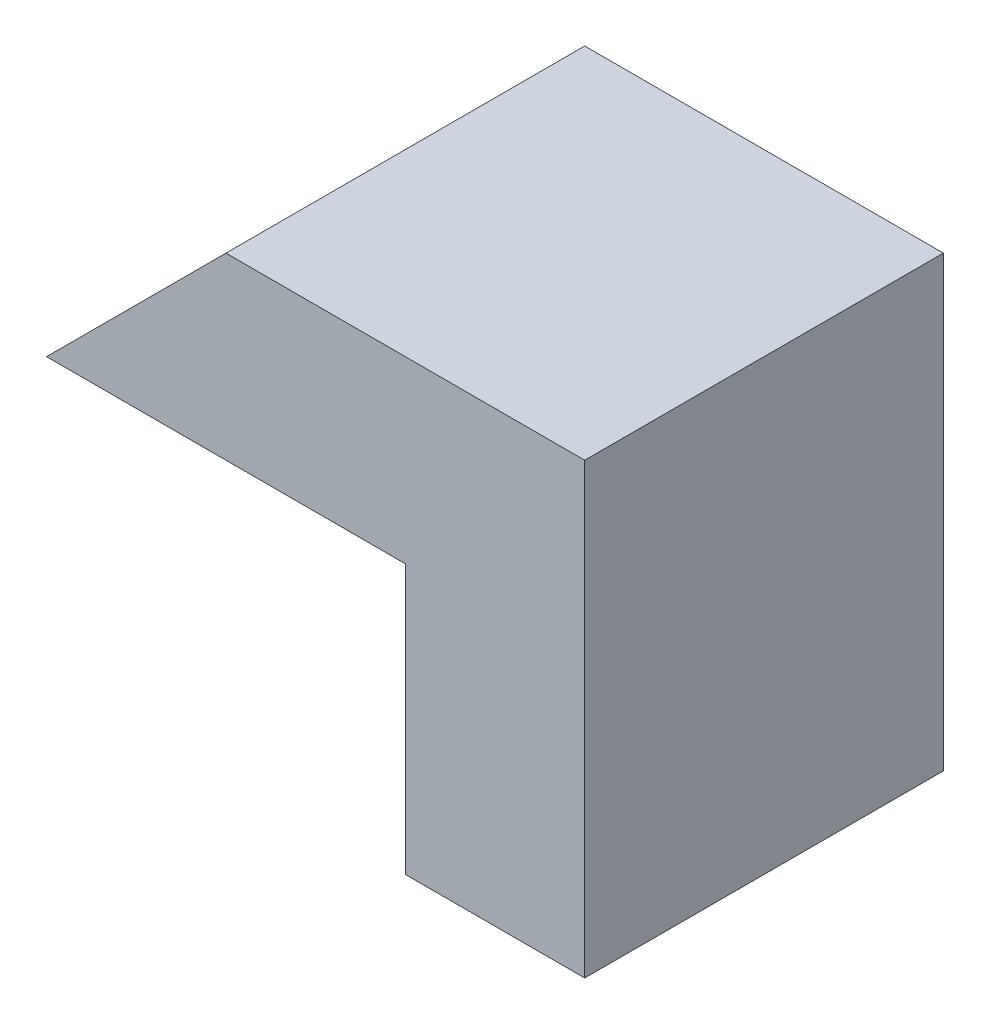
from build123d import *

# Parameters (mm, degrees)
SKETCH2_W           = 6
SKETCH2_H           = 4
BOSS_EXTRUDE1_DEPTH = 5
SKETCH3_W           = 1
SKETCH3_H           = 3
CUT_EXTRUDE1_DEPTH  = 5
CUT_EXTRUDE2_DEPTH  = 3


with BuildPart() as part:
    # Sketch2 → Boss-Extrude1 (new body)
    with BuildSketch(Plane(origin=(0, 0, 0), x_dir=(1, 0, 0), z_dir=(0, 1, 0))):
        with Locations((3, 2)):
            Rectangle(SKETCH2_W, SKETCH2_H)
    extrude(amount=BOSS_EXTRUDE1_DEPTH)

    # Sketch3 → Cut-Extrude1 (cut)
    with BuildSketch(Plane.XY):
        Polygon((0, 5), (0, 3), (2, 5), align=None)
        with Locations((0.5, 1.5)):
            Rectangle(SKETCH3_W, SKETCH3_H)
    extrude(amount=-CUT_EXTRUDE1_DEPTH, mode=Mode.SUBTRACT)

    # Sketch4 → Cut-Extrude2 (cut)
    with BuildSketch(Plane.XZ):
        Polygon((1, -4), (4, 0), (1, 0), align=None)
    extrude(amount=-CUT_EXTRUDE2_DEPTH, mode=Mode.SUBTRACT)


solid = part.part
